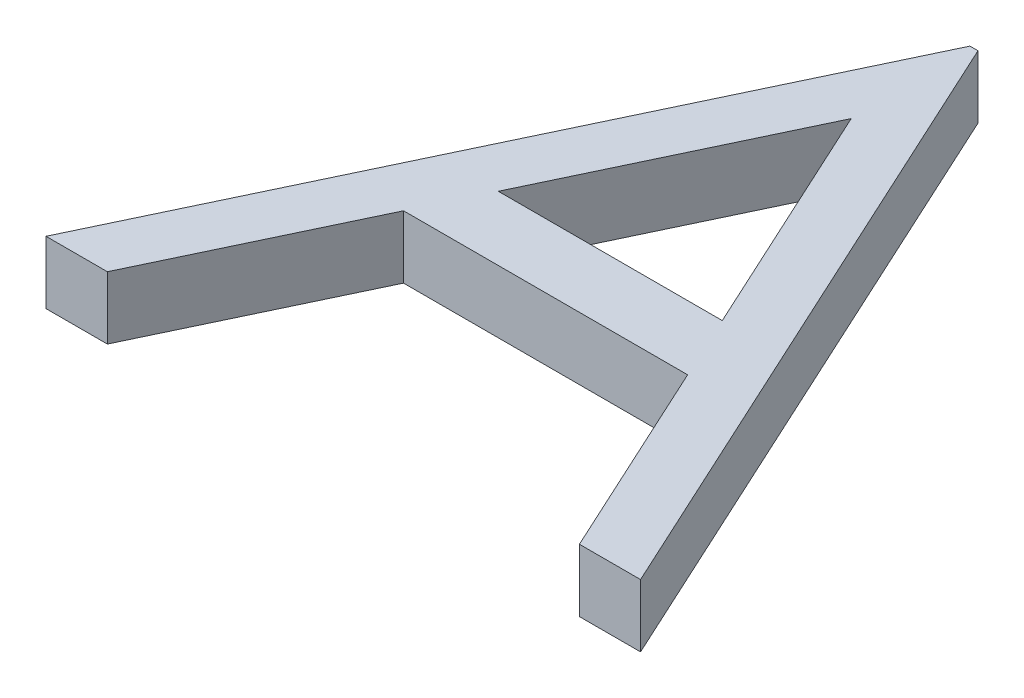
from build123d import *

# Parameters (mm, degrees)
BOSS_EXTRUDE2_DEPTH = 2.54


with BuildPart() as part:
    # Sketch3 → Boss-Extrude2 (new body)
    with BuildSketch(Plane(origin=(0, 0, 0), x_dir=(1, 0, 0), z_dir=(0, 1, 0))):
        Polygon((13.676923077, 25.4), (25.4, 0), (22.922075321, 0), (19.167027244, 8.141025641), (7.652564103, 8.141025641), (3.790665064, 0), (1.302564103, 0), (13.351282051, 25.4), align=None)
        Polygon((13.488661859, 20.449238782), (8.888982372, 10.746153846), (17.966225962, 10.746153846), align=None, mode=Mode.SUBTRACT)
    extrude(amount=BOSS_EXTRUDE2_DEPTH)


solid = part.part
